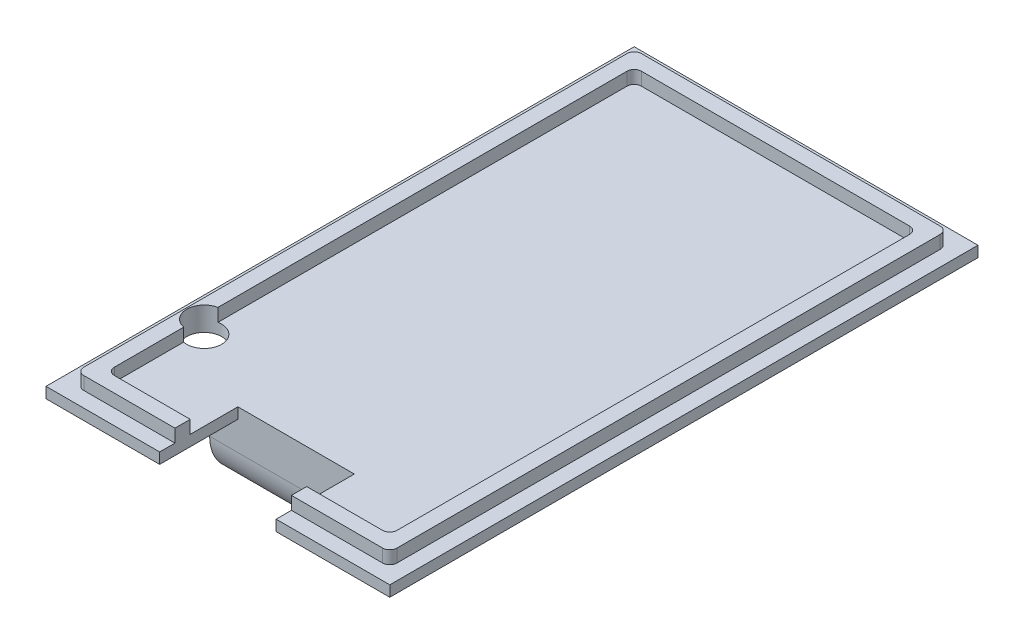
from build123d import *

# Parameters (mm, degrees)
PCB_DIMENSIONS_W    = 47.716732244
PCB_DIMENSIONS_H    = 81.636732244
BOSS_EXTRUDE3_DEPTH = 1.5
SKETCH5_W           = 43.474091557
SKETCH5_H           = 77.394091557
SKETCH5_W_2         = 39.23145087
SKETCH5_H_2         = 73.15145087
BOSS_EXTRUDE4_DEPTH = 1.8
FILLET1_R           = 1
SKETCH6_W           = 12
SKETCH6_H           = 29.966906412
SKETCH6_H_2         = 34.033093588
BOSS_EXTRUDE5_DEPTH = 10
SKETCH7_W           = 48
SKETCH7_H           = 6
CUT_EXTRUDE1_DEPTH  = 24
FILLET2_R           = 6
FILLET3_R           = 1
SCALE1_SCALE        = 0.99
CUT_EXTRUDE2_DEPTH  = 10
SKETCH9_R           = 2.4
CUT_EXTRUDE3_DEPTH  = 10


with BuildPart() as part:
    # PCB Dimensions → Boss-Extrude3 (new body)
    with BuildSketch(Plane(origin=(0, 0, 0), x_dir=(1, 0, 0), z_dir=(0, 1, 0))):
        with Locations((20.322832216, -37.282832216)):
            Rectangle(PCB_DIMENSIONS_W, PCB_DIMENSIONS_H)
    extrude(amount=BOSS_EXTRUDE3_DEPTH)

    # Sketch5 → Boss-Extrude4 (add)
    with BuildSketch(Plane(origin=(0, 1.5, 0), x_dir=(1, 0, 0), z_dir=(0, 1, 0))):
        with Locations((20.322832217, -37.282832217)):
            Rectangle(SKETCH5_W, SKETCH5_H)
        with Locations((20.322832216, -37.282832216)):
            Rectangle(SKETCH5_W_2, SKETCH5_H_2, mode=Mode.SUBTRACT)
    extrude(amount=BOSS_EXTRUDE4_DEPTH)

    # Fillet1
    fillet1_edges = [part.edges().sort_by_distance(p)[0] for p in [
        (-1.414213562, 2.4, -1.414213562),
        (-1.414213562, 2.4, 75.979877995),
        (42.059877995, 2.4, 75.979877995),
        (42.059877995, 2.4, -1.414213562),
        (0.707106781, 2.4, 0.707106781),
        (0.707106781, 2.4, 73.858557651),
        (39.938557651, 2.4, 73.858557651),
        (39.938557651, 2.4, 0.707106781),
    ]]
    fillet(fillet1_edges, radius=FILLET1_R)

    # Sketch6 → Boss-Extrude5 (add)
    with BuildSketch(Plane.XZ):
        with Locations((14.322832216, 52.266285422)):
            Rectangle(SKETCH6_W, SKETCH6_H)
        with Locations((26.322832216, 52.266285422)):
            Rectangle(SKETCH6_W, SKETCH6_H)
        with Locations((14.322832216, 20.266285422)):
            Rectangle(SKETCH6_W, SKETCH6_H_2)
        with Locations((26.322832216, 20.266285422)):
            Rectangle(SKETCH6_W, SKETCH6_H_2)
    extrude(amount=BOSS_EXTRUDE5_DEPTH)

    # Sketch7 → Cut-Extrude1 (cut)
    with BuildSketch(Plane(origin=(32.322832216, 0, 0), x_dir=(0, 0, -1), z_dir=(1, 0, 0))):
        with Locations((-35.249738628, -3)):
            Rectangle(SKETCH7_W, SKETCH7_H)
    extrude(amount=-CUT_EXTRUDE1_DEPTH, mode=Mode.SUBTRACT)

    # Fillet2
    fillet2_edges = [part.edges().sort_by_distance(p)[0] for p in [
        (20.322832216, -10, 67.249738628),
        (20.322832216, -10, 3.249738628),
    ]]
    fillet(fillet2_edges, radius=FILLET2_R)

    # Fillet3
    fillet3_edges = [part.edges().sort_by_distance(p)[0] for p in [
        (20.322832216, -6, 59.249738628),
        (20.322832216, -6, 11.249738628),
    ]]
    fillet(fillet3_edges, radius=FILLET3_R)


with BuildPart() as part_1:
    # Scale1: scaled about (20.322832216, -3.130115188, 36.173441116)
    add(part.part.scale(SCALE1_SCALE).moved(Location((0.203228322, -0.031301152, 0.361734411))))

    # Sketch8 → Cut-Extrude2 (cut)
    with BuildSketch(Plane.XZ.offset(0.031301152)):
        Polygon((20.322832216, 77.681920766), (12.322832216, 77.681920766), (12.322832216, 66.938975653), (28.322832216, 66.938975653), (28.322832216, 77.681920766), align=None)
    extrude(amount=-CUT_EXTRUDE2_DEPTH, mode=Mode.SUBTRACT)

    # Sketch9 → Cut-Extrude3 (cut)
    with BuildSketch(Plane.XZ.offset(0.031301152)):
        with Locations((1.373049755, 60.612830152)):
            Circle(SKETCH9_R)
    extrude(amount=-CUT_EXTRUDE3_DEPTH, mode=Mode.SUBTRACT)


solid = part_1.part
